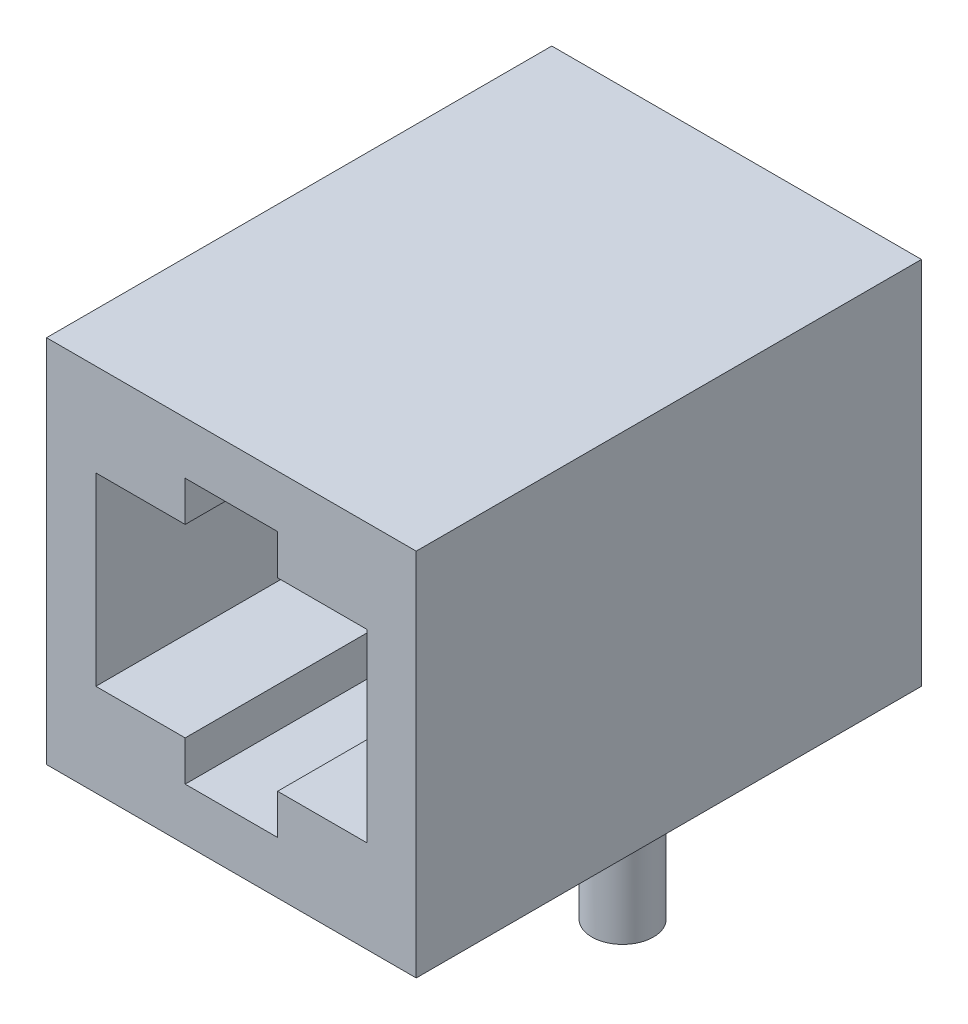
from build123d import *

# Parameters (mm, degrees)
SKETCH1_W           = 15.24
SKETCH1_H           = 15.24
BOSS_EXTRUDE1_DEPTH = 20.828
CUT_EXTRUDE1_DEPTH  = 18.288
SKETCH3_R           = 1.27
BOSS_EXTRUDE2_DEPTH = 4.064


with BuildPart() as part:
    # Sketch1 → Boss-Extrude1 (new body)
    with BuildSketch(Plane.XY):
        Rectangle(SKETCH1_W, SKETCH1_H)
    extrude(amount=BOSS_EXTRUDE1_DEPTH)

    # Sketch2 → Cut-Extrude1 (cut)
    with BuildSketch(Plane.XY.offset(20.828)):
        Polygon((5.588, -3.81), (1.905, -3.81), (1.905, -5.461), (-1.905, -5.461), (-1.905, -3.81), (-5.588, -3.81), (-5.588, 3.81), (-1.905, 3.81), (-1.905, 5.461), (1.905, 5.461), (1.905, 3.81), (5.588, 3.81), align=None)
    extrude(amount=-CUT_EXTRUDE1_DEPTH, mode=Mode.SUBTRACT)

    # Sketch3 → Boss-Extrude2 (add)
    with BuildSketch(Plane.XZ.offset(7.62)):
        with Locations((-5.715, 10.414)):
            Circle(SKETCH3_R)
        with Locations((5.715, 10.414)):
            Circle(SKETCH3_R)
    extrude(amount=BOSS_EXTRUDE2_DEPTH)


solid = part.part
